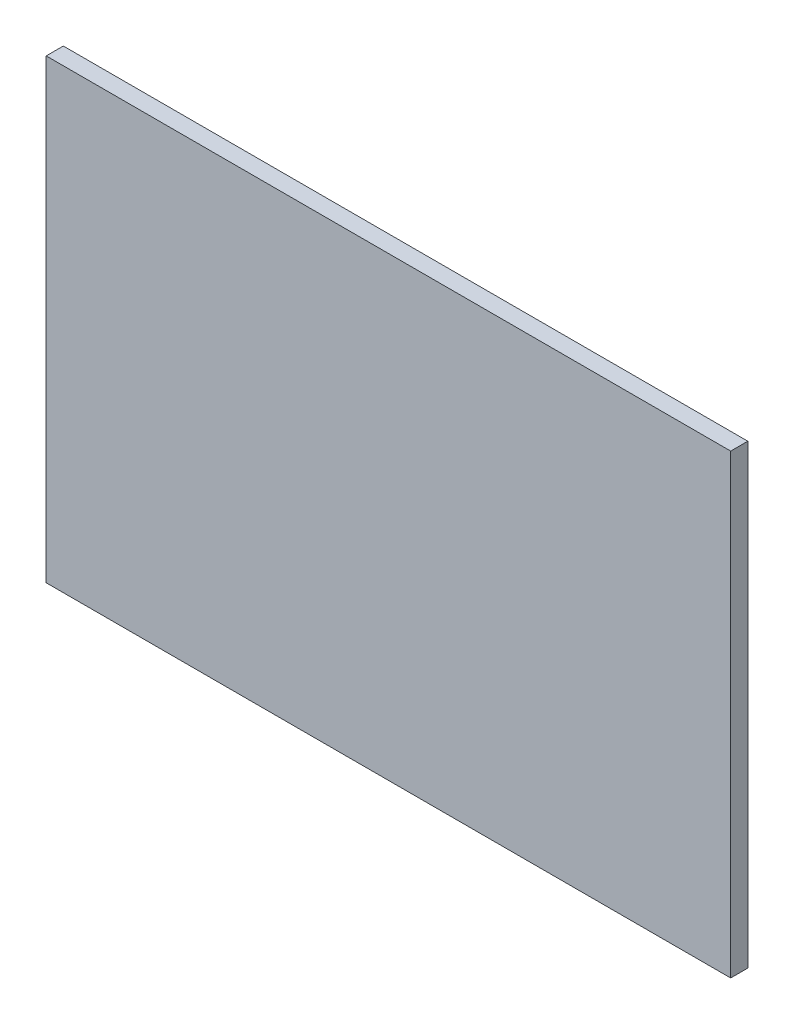
from build123d import *

# Parameters (mm, degrees)
CROQUIS1_W              = 600
CROQUIS1_H              = 400
SALIENTE_EXTRUIR1_DEPTH = 15


with BuildPart() as part:
    # Croquis1 → Saliente-Extruir1 (new body)
    with BuildSketch(Plane.XY):
        Rectangle(CROQUIS1_W, CROQUIS1_H)
    extrude(amount=SALIENTE_EXTRUIR1_DEPTH)


solid = part.part
